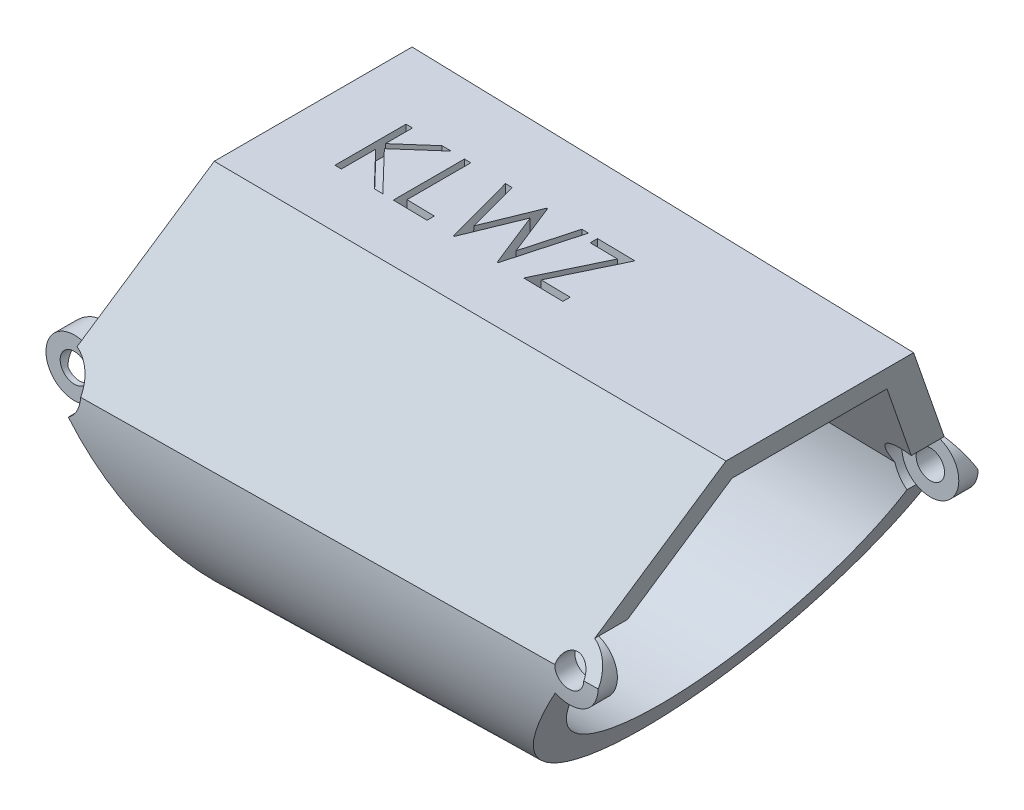
from build123d import *

# Parameters (mm, degrees)
BOSS_EXTRUDE1_DEPTH     = 25.4
BOSS_EXTRUDE1_TAPER     = 1
SHELL1_T                = -1.27
BOSS_EXTRUDE2_DEPTH     = 1.27
SKETCH2_R               = 0.635
CUT_EXTRUDE1_DEPTH      = 9.904502557
CUT_EXTRUDE1_DEPTH_BACK = 9.904502557
SKETCH5_R               = 1.27
CUT_EXTRUDE3_DEPTH      = 7.874
SKETCH6_R               = 1.27
CUT_EXTRUDE4_DEPTH      = 7.62
CUT_EXTRUDE4_DEPTH_BACK = 7.62
CUT_EXTRUDE2_DEPTH      = 0.762


with BuildPart() as part:
    # Sketch1 → Boss-Extrude1 (new body)
    with BuildSketch(Plane(origin=(0, 0, 0), x_dir=(0, 0, -1), z_dir=(1, 0, 0))):
        with BuildLine():
            Line((-4.445, 0), (-8.89, -7.69896584))
            ThreePointArc((-8.89, -7.69896584), (0, -17.111468296), (8.89, -7.69896584))
            Line((8.89, -7.69896584), (4.445, 0))
            Line((4.445, 0), (-4.445, 0))
        make_face()
    extrude(amount=BOSS_EXTRUDE1_DEPTH, taper=BOSS_EXTRUDE1_TAPER)

    # Shell1
    shell1_openings = [part.faces().sort_by_distance(p)[0] for p in [
        (25.4, -6.345754324, 0),
        (0, -6.202608534, 0),
    ]]
    offset(amount=SHELL1_T, openings=shell1_openings, kind=Kind.INTERSECTION)

    # Sketch4 → Boss-Extrude2 (add)
    with BuildSketch(Plane.ZY):
        with BuildLine():
            Line((-8.156765158, -6.42896584), (-6.69007209, -6.42896584))
            Line((-6.69007209, -6.42896584), (-7.63293346, -8.062049637))
            ThreePointArc((-7.63293346, -8.062049637), (-7.628049436, -8.516054357), (-7.596185221, -8.96896584))
            Line((-7.596185221, -8.96896584), (-8.871838592, -8.96896584))
            ThreePointArc((-8.871838592, -8.96896584), (-8.903592114, -8.334290068), (-8.89, -7.69896584))
            Line((-8.89, -7.69896584), (-8.156765158, -6.42896584))
        make_face()
        with BuildLine():
            Line((8.871838592, -8.96896584), (7.596185221, -8.96896584))
            ThreePointArc((7.596185221, -8.96896584), (7.628049436, -8.516054357), (7.63293346, -8.062049637))
            Line((7.63293346, -8.062049637), (6.69007209, -6.42896584))
            Line((6.69007209, -6.42896584), (8.156765158, -6.42896584))
            Line((8.156765158, -6.42896584), (8.89, -7.69896584))
            ThreePointArc((8.89, -7.69896584), (8.903592114, -8.334290068), (8.871838592, -8.96896584))
        make_face()
    extrude(amount=BOSS_EXTRUDE2_DEPTH)

    # Sketch2 → Cut-Extrude1 (cut, two sides)
    with BuildSketch(Plane.XY) as cut_extrude1_sk:
        with Locations((0, -7.69896584)):
            Circle(SKETCH2_R)
        with Locations((22.717065731, -7.814659971)):
            Circle(SKETCH2_R)
        with BuildLine():
            Line((25.4, -0.443358649), (23.151431313, -6.621250342))
            ThreePointArc((23.151431313, -6.621250342), (23.868076621, -8.351385163), (22.082065731, -8.914512233))
            Line((22.082065731, -8.914512233), (17.52617423, -16.805547787))
            Line((17.52617423, -16.805547787), (25.4, -16.668109647))
            Line((25.4, -16.668109647), (25.4, -0.443358649))
        make_face()
        with BuildLine():
            Line((-2.129601865, -17.485197771), (-2.129601865, 2.087266092))
            Line((-2.129601865, 2.087266092), (3.561897129, 2.087266092))
            Line((3.561897129, 2.087266092), (0.434365582, -6.505556211))
            ThreePointArc((0.434365582, -6.505556211), (-1.259134974, -7.864734104), (0.728442074, -8.739288936))
            Line((0.728442074, -8.739288936), (6.852393369, -17.485197771))
            Line((6.852393369, -17.485197771), (-2.129601865, -17.485197771))
        make_face()
    extrude(amount=CUT_EXTRUDE1_DEPTH, mode=Mode.SUBTRACT)
    extrude(cut_extrude1_sk.sketch, amount=-CUT_EXTRUDE1_DEPTH_BACK, mode=Mode.SUBTRACT)

    # Sketch5 → Cut-Extrude3 (cut)
    with BuildSketch(Plane.XY.offset(7.874)):
        with Locations((0, -7.69896584)):
            Circle(SKETCH5_R)
    cut_extrude3 = extrude(amount=CUT_EXTRUDE3_DEPTH, mode=Mode.SUBTRACT)

    # Mirror1: Cut-Extrude3 across plane
    add(cut_extrude3.mirror(Plane.XY), mode=Mode.SUBTRACT)

    # Sketch6 → Cut-Extrude4 (cut, two sides)
    with BuildSketch(Plane.XY) as cut_extrude4_sk:
        with Locations((22.717065731, -7.814659971)):
            Circle(SKETCH6_R)
    extrude(amount=CUT_EXTRUDE4_DEPTH, mode=Mode.SUBTRACT)
    extrude(cut_extrude4_sk.sketch, amount=-CUT_EXTRUDE4_DEPTH_BACK, mode=Mode.SUBTRACT)

    # Sketch3 → Cut-Extrude2 (cut)
    with BuildSketch(Plane(origin=(0, 0, 0), x_dir=(0.999847695, -0.017452406, 0), z_dir=(0.017452406, 0.999847695, 0))):
        Polygon((5.585214656, 1.348472387), (5.870150554, 1.348472387), (5.870150554, 0.139402876), (7.193703238, 1.348472387), (7.600118502, 1.348472387), (6.03996726, -0.0762071), (7.722233887, -1.826527613), (7.342531363, -1.826527613), (5.870150554, -0.294361146), (5.870150554, -1.826527613), (5.585214656, -1.826527613), align=None)
        Polygon((8.190342861, 1.348472387), (8.475278759, 1.348472387), (8.475278759, -1.500886587), (9.696432605, -1.500886587), (9.696432605, -1.826527613), (8.190342861, -1.826527613), align=None)
        Polygon((10.022073631, 1.348472387), (10.316549793, 1.348472387), (10.937939015, -0.979988149), (11.862072629, 1.348472387), (11.903413775, 1.348472387), (12.810374913, -0.964087709), (13.434944224, 1.348472387), (13.726240297, 1.348472387), (12.87016057, -1.826527613), (12.829455442, -1.826527613), (11.874156964, 0.601787692), (10.907410169, -1.826527613), (10.866705041, -1.826527613), align=None)
        Polygon((14.133291579, 1.022831362), (14.133291579, 1.348472387), (15.802201836, 1.348472387), (14.470380922, -1.500886587), (15.761496708, -1.500886587), (15.761496708, -1.826527613), (14.011176195, -1.826527613), (15.342997108, 1.022831362), align=None)
    extrude(amount=-CUT_EXTRUDE2_DEPTH, mode=Mode.SUBTRACT)


solid = part.part
